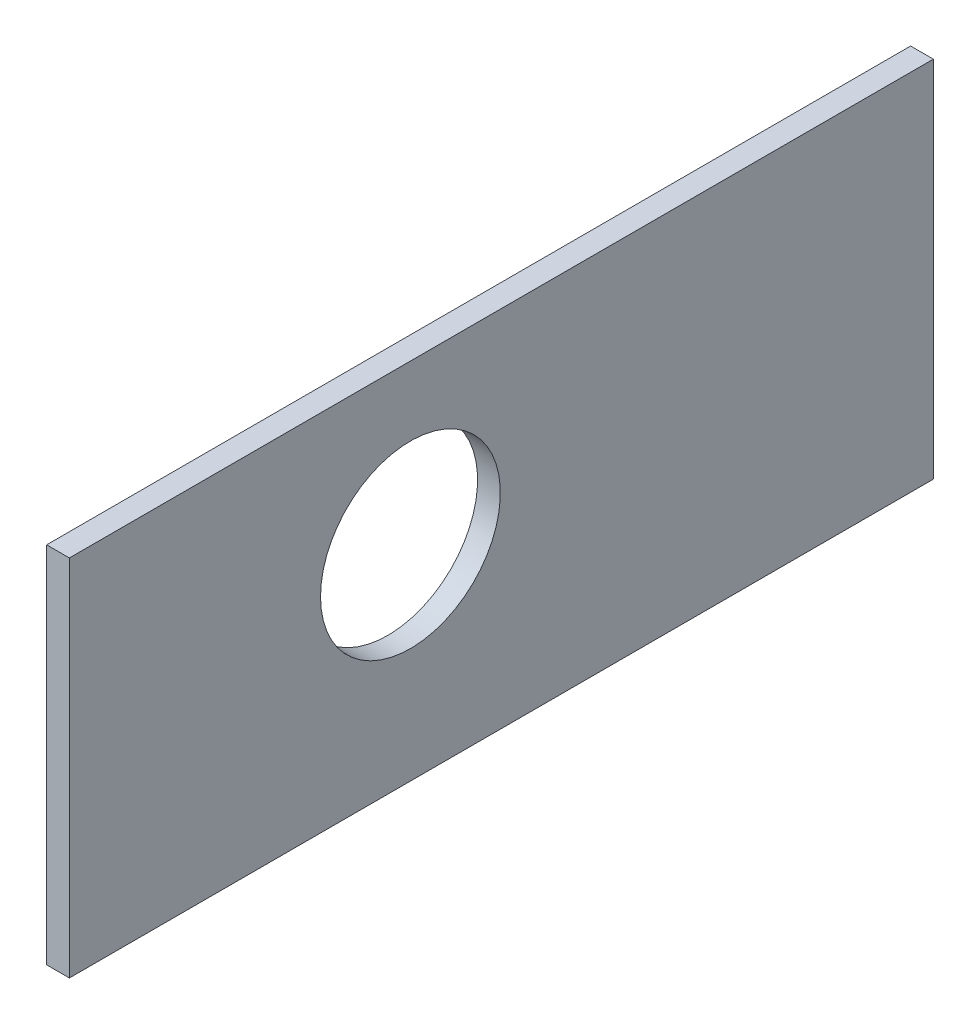
from build123d import *

# Parameters (mm, degrees)
SKETCH1_W           = 203.2
SKETCH1_H           = 120.65
BOSS_EXTRUDE1_DEPTH = 50.8
SKETCH2_W           = 196.85
SKETCH2_H           = 114.3
CUT_EXTRUDE1_DEPTH  = 51.8
SKETCH4_W           = 203.2
SKETCH4_H           = 120.65
SKETCH4_W_2         = 196.85
SKETCH4_H_2         = 114.3
BOSS_EXTRUDE2_DEPTH = 6.35
CUT_EXTRUDE5_DEPTH  = 121.65
CUT_EXTRUDE6_REACH  = 205.2
CUT_EXTRUDE7_REACH  = 205.2
SKETCH13_R          = 12.55395
CUT_EXTRUDE8_DEPTH  = 51.8


with BuildPart() as part:
    # Sketch1 → Boss-Extrude1 (new body)
    with BuildSketch(Plane(origin=(0, 0, 0), x_dir=(1, 0, 0), z_dir=(0, 1, 0))):
        Rectangle(SKETCH1_W, SKETCH1_H)
    extrude(amount=BOSS_EXTRUDE1_DEPTH)

    # Sketch2 → Cut-Extrude1 (cut, through all)
    with BuildSketch(Plane(origin=(0, 50.8, 0), x_dir=(1, 0, 0), z_dir=(0, 1, 0))):
        Rectangle(SKETCH2_W, SKETCH2_H)
    extrude(amount=-CUT_EXTRUDE1_DEPTH, mode=Mode.SUBTRACT)

    # Sketch4 → Boss-Extrude2 (add)
    with BuildSketch(Plane(origin=(0, 50.8, 0), x_dir=(1, 0, 0), z_dir=(0, 1, 0))):
        Rectangle(SKETCH4_W, SKETCH4_H)
        Rectangle(SKETCH4_W_2, SKETCH4_H_2, mode=Mode.SUBTRACT)
    extrude(amount=-BOSS_EXTRUDE2_DEPTH)

    # Sketch10 → Cut-Extrude5 (cut, through all)
    with BuildSketch(Plane.XY.offset(60.325)):
        with BuildLine():
            ThreePointArc((-65.9511, 22.225), (-81.206975571, 31.167602912), (-81.556705839, 13.4874))
            Line((-81.556705839, 13.4874), (-70.843294161, 13.4874))
            ThreePointArc((-70.843294161, 13.4874), (-67.257397088, 17.218024429), (-65.9511, 22.225))
        make_face()
        with BuildLine():
            ThreePointArc((-15.1511, 22.225), (-30.406975571, 31.167602912), (-30.756705839, 13.4874))
            Line((-30.756705839, 13.4874), (-20.043294161, 13.4874))
            ThreePointArc((-20.043294161, 13.4874), (-16.457397088, 17.218024429), (-15.1511, 22.225))
        make_face()
        with BuildLine():
            ThreePointArc((35.6489, 22.225), (20.393024429, 31.167602912), (20.043294161, 13.4874))
            Line((20.043294161, 13.4874), (30.756705839, 13.4874))
            ThreePointArc((30.756705839, 13.4874), (34.342602912, 17.218024429), (35.6489, 22.225))
        make_face()
        with BuildLine():
            Line((70.843294161, 13.4874), (81.556705839, 13.4874))
            ThreePointArc((81.556705839, 13.4874), (85.142602912, 17.218024429), (86.4489, 22.225))
            ThreePointArc((86.4489, 22.225), (71.193024429, 31.167602912), (70.843294161, 13.4874))
        make_face()
    extrude(amount=-CUT_EXTRUDE5_DEPTH, mode=Mode.SUBTRACT)

    # Sketch12 → Cut-Extrude6 (cut, up to next)
    with BuildSketch(Plane(origin=(101.6, 0, 0), x_dir=(0, 0, -1), z_dir=(1, 0, 0)), mode=Mode.PRIVATE) as cut_extrude6_sk1:
        with BuildLine():
            ThreePointArc((-16.868294161, 13.4874), (-22.225, 32.4739), (-27.581705839, 13.4874))
            Line((-27.581705839, 13.4874), (-16.868294161, 13.4874))
        make_face()
    cut_extrude6_tool1 = extrude(cut_extrude6_sk1.sketch, amount=-CUT_EXTRUDE6_REACH, mode=Mode.PRIVATE) & part.part
    add(cut_extrude6_tool1.solids().sort_by_distance((101.6, 22.546198, 22.225))[0], mode=Mode.SUBTRACT)
    # Sketch12 → Cut-Extrude6 (cut, up to next)
    with BuildSketch(Plane(origin=(101.6, 0, 0), x_dir=(0, 0, -1), z_dir=(1, 0, 0)), mode=Mode.PRIVATE) as cut_extrude6_sk2:
        with BuildLine():
            ThreePointArc((27.581705839, 13.4874), (22.225, 32.4739), (16.868294161, 13.4874))
            Line((16.868294161, 13.4874), (27.581705839, 13.4874))
        make_face()
    cut_extrude6_tool2 = extrude(cut_extrude6_sk2.sketch, amount=-CUT_EXTRUDE6_REACH, mode=Mode.PRIVATE) & part.part
    add(cut_extrude6_tool2.solids().sort_by_distance((101.6, 22.546198, -22.225))[0], mode=Mode.SUBTRACT)

    # Sketch13 → Cut-Extrude7 (cut, up to next)
    with BuildSketch(Plane.ZY.offset(101.6), mode=Mode.PRIVATE) as cut_extrude7_sk1:
        with Locations((12.7, 28.575)):
            Circle(SKETCH13_R)
    cut_extrude7_tool1 = extrude(cut_extrude7_sk1.sketch, amount=-CUT_EXTRUDE7_REACH, mode=Mode.PRIVATE) & part.part
    add(cut_extrude7_tool1.solids().sort_by_distance((-101.6, 28.575, 12.7))[0], mode=Mode.SUBTRACT)

    # Sketch14 → Cut-Extrude8 (cut, through all)
    with BuildSketch(Plane(origin=(0, 50.8, 0), x_dir=(1, 0, 0), z_dir=(0, 1, 0))):
        Polygon((-98.425, -57.15), (-98.425, -60.325), (101.6, -60.325), (101.6, 60.325), (-98.425, 60.325), align=None)
    extrude(amount=-CUT_EXTRUDE8_DEPTH, mode=Mode.SUBTRACT)


solid = part.part
